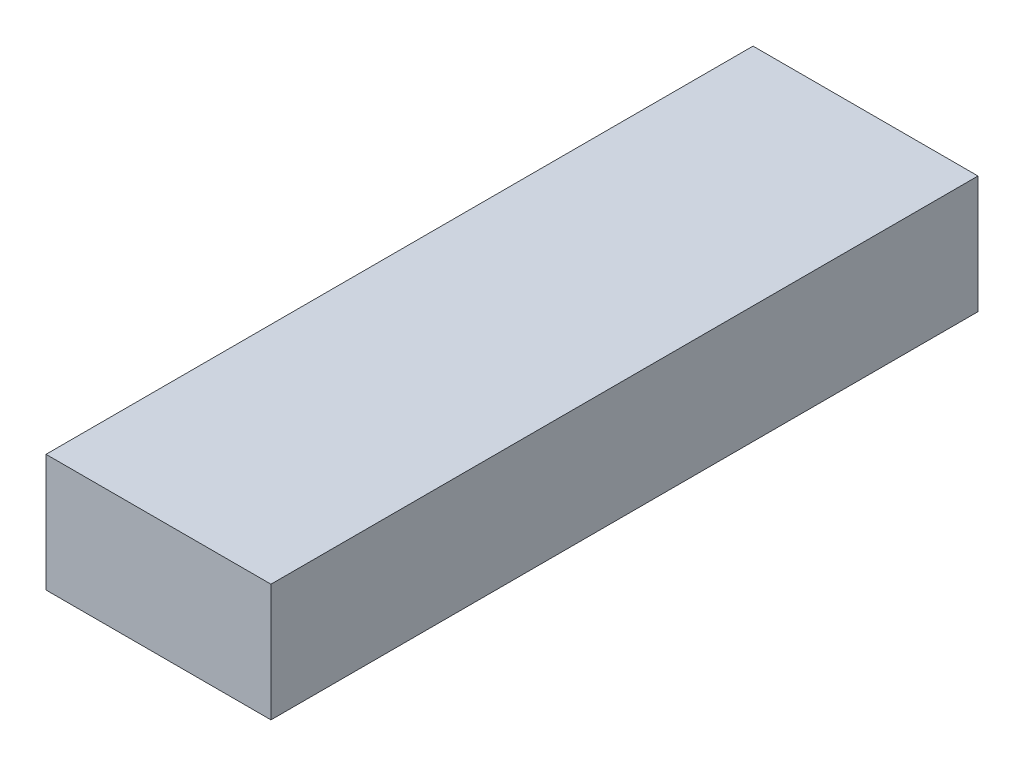
from build123d import *

# Parameters (mm, degrees)
SKETCH1_W           = 49
SKETCH1_H           = 25.6
BOSS_EXTRUDE1_DEPTH = 154


with BuildPart() as part:
    # Sketch1 → Boss-Extrude1 (new body)
    with BuildSketch(Plane.XY):
        Rectangle(SKETCH1_W, SKETCH1_H)
    extrude(amount=BOSS_EXTRUDE1_DEPTH)


solid = part.part
